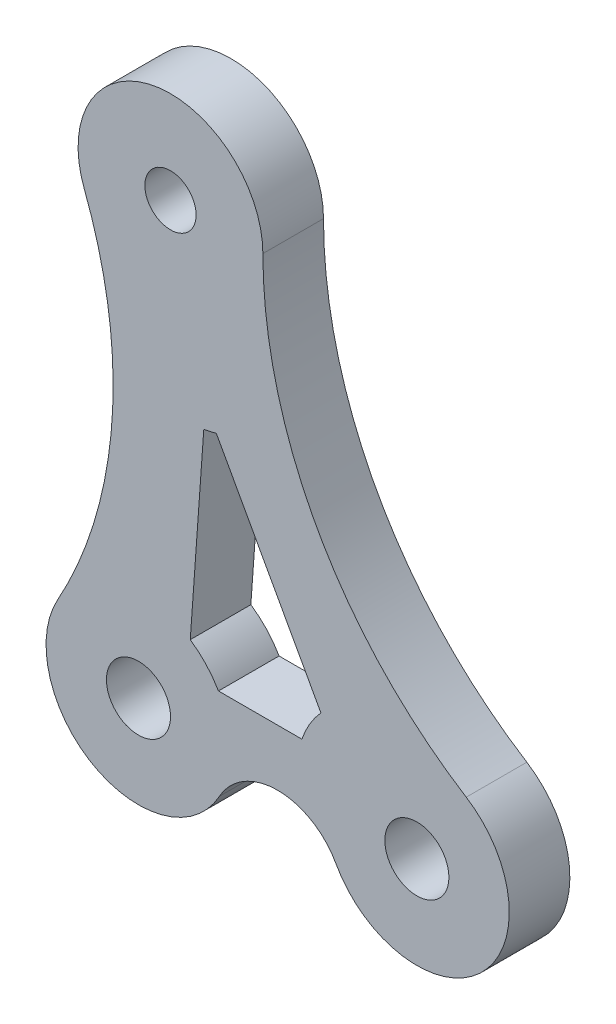
from build123d import *

# Parameters (mm, degrees)
CROQUIS1_R              = 1.651
CROQUIS1_R_2            = 1.3208
SALIENTE_EXTRUIR1_DEPTH = 3.1242
CORTAR_EXTRUIR1_DEPTH   = 3.1242


with BuildPart() as part:
    # Croquis1 → Saliente-Extruir1 (new body)
    with BuildSketch(Plane.XY):
        with BuildLine():
            ThreePointArc((2.520278818, -2.298225244), (5.5245, -0.523415469), (8.528721182, -2.298225244))
            ThreePointArc((8.528721182, -2.298225244), (15.964986845, -3.467169905), (15.244404767, 4.025842847))
            ThreePointArc((15.244404767, 4.025842847), (7.556394525, 12.189930179), (4.7625, 23.0505))
            ThreePointArc((4.7625, 23.0505), (-0.866847253, 27.733445877), (-4.446941298, 21.345765609))
            ThreePointArc((-4.446941298, 21.345765609), (-3.013234987, 11.681947272), (-5.809588918, 2.321108456))
            ThreePointArc((-5.809588918, 2.321108456), (-3.960675565, -4.164949584), (2.520278818, -2.298225244))
        make_face()
        with Locations((-1.651, 0)):
            Circle(CROQUIS1_R, mode=Mode.SUBTRACT)
        Polygon((4.638514436, 4.7625), (3.464816339, 4.7625), (3.599843554, 6.647687651), align=None, mode=Mode.SUBTRACT)
        with Locations((0, 23.0505)):
            Circle(CROQUIS1_R_2, mode=Mode.SUBTRACT)
        with Locations((12.7, 0)):
            Circle(CROQUIS1_R, mode=Mode.SUBTRACT)
    extrude(amount=SALIENTE_EXTRUIR1_DEPTH)

    # Croquis2 → Cortar-Extruir1 (cut)
    with BuildSketch(Plane.XY.offset(3.1242)):
        with BuildLine():
            ThreePointArc((6.772401381, 2.38125), (7.178118311, 3.26217793), (7.753887726, 4.042645627))
            Line((7.753887726, 4.042645627), (2.361995667, 13.828929715))
            ThreePointArc((2.361995667, 13.828929715), (2.041810785, 13.746918232), (1.71670875, 13.687311946))
            Line((1.71670875, 13.687311946), (1.018825269, 3.943784893))
            ThreePointArc((1.018825269, 3.943784893), (1.834815442, 3.24507272), (2.473445986, 2.38125))
            Line((2.473445986, 2.38125), (6.772401381, 2.38125))
        make_face()
    extrude(amount=-CORTAR_EXTRUIR1_DEPTH, mode=Mode.SUBTRACT)


solid = part.part
